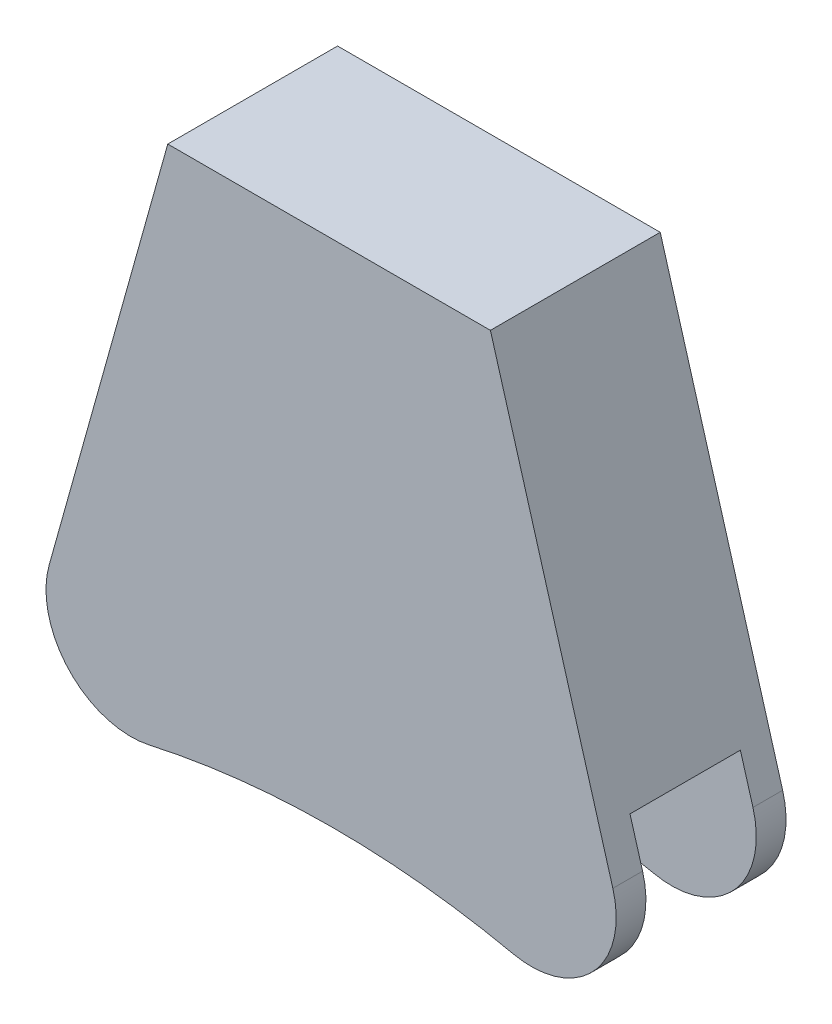
from build123d import *

# Parameters (mm, degrees)
BOSS_EXTRUDE1_DEPTH = 10
SKETCH5_W           = 13
SKETCH5_H           = 100
FILLET1_R           = 10


with BuildPart() as part:
    # Sketch1 → Boss-Extrude1 (new body, symmetric)
    with BuildSketch(Plane.XY):
        with BuildLine():
            Line((17.04861701, 0), (36.638934873, -67.52052444))
            ThreePointArc((36.638934873, -67.52052444), (-1.647556066, -60.00028765), (-39.897531443, -67.704100565))
            Line((-39.897531443, -67.704100565), (-20.95138299, 0))
            Line((-20.95138299, 0), (17.04861701, 0))
        make_face()
    extrude(amount=BOSS_EXTRUDE1_DEPTH, both=True)

    # Sketch5 → Cut-Revolve2 (revolve, cut)
    with BuildSketch(Plane(origin=(0, 0, 0), x_dir=(0, 0, -1), z_dir=(1, 0, 0))):
        with Locations((0, -190)):
            Rectangle(SKETCH5_W, SKETCH5_H)
    revolve(axis=Axis((0, -140, 0), (0, 0, -1)), mode=Mode.SUBTRACT)

    # Fillet1
    fillet1_edges = [part.edges().sort_by_distance(p)[0] for p in [
        (36.638934873, -67.52052444, -8.25),
        (-39.897531443, -67.704100565, -8.25),
        (-39.897531443, -67.704100565, 8.25),
        (36.638934873, -67.52052444, 8.25),
    ]]
    fillet(fillet1_edges, radius=FILLET1_R)


solid = part.part
